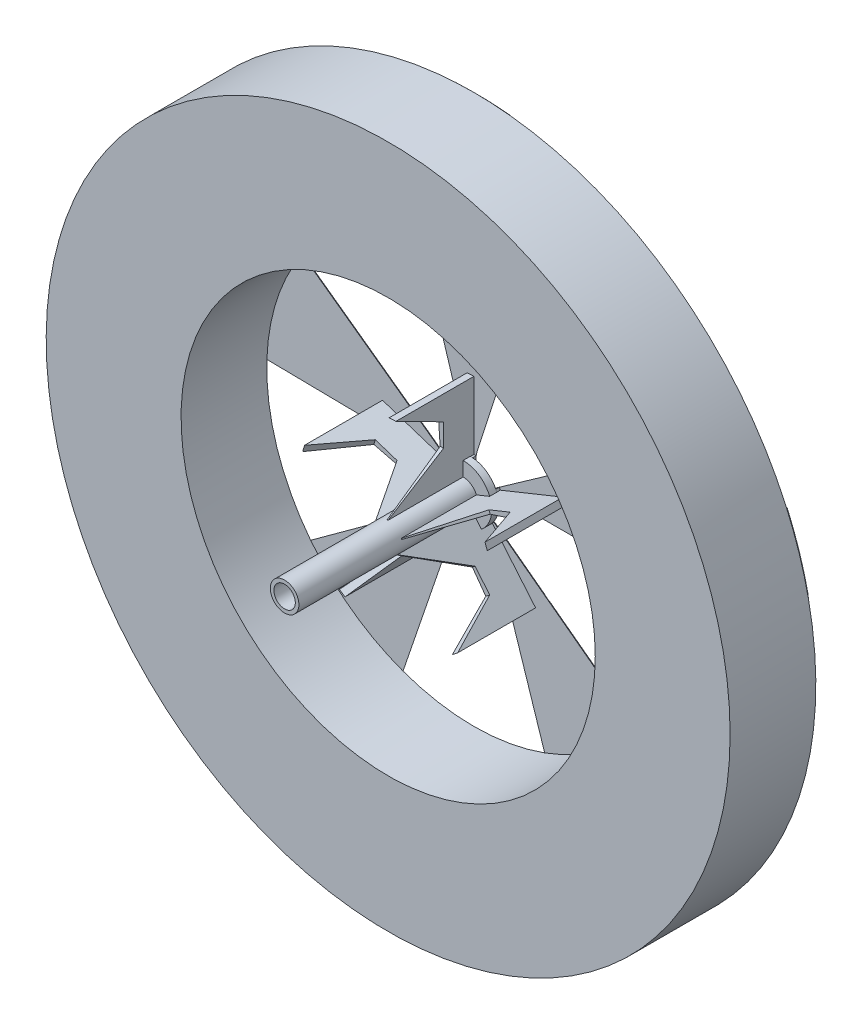
from build123d import *

# Parameters (mm, degrees)
ESQUISSE1_R                  = 47.881441282
ESQUISSE1_R_2                = 28.998911711
BOSS_EXTRU_1_DEPTH           = 12
ESQUISSE3_R                  = 4
BOSS_EXTRU_2_DEPTH           = 1
ESQUISSE4_R                  = 2
ESQUISSE4_R_2                = 1.8
ENL_V_MAT_EXTRU_1_DEPTH      = 0.2
BOSS_EXTRU_3_DEPTH           = 0.3
BOSS_EXTRU_3_TAPER           = 45
BOSS_EXTRU_4_DEPTH           = 0.5
ESQUISSE7_R                  = 0.544673449
ENL_V_MAT_EXTRU_3_DEPTH      = 0.1
ENL_V_MAT_EXTRU_4_DEPTH      = 0.1
ENL_V_MAT_EXTRU_5_DEPTH      = 0.1
R_P_TITION_CIRCULAIRE1_COUNT = 5
ESQUISSE12_R                 = 2
ESQUISSE12_R_2               = 1.5
BOSS_EXTRU_5_DEPTH           = 25
R_VOLUTION1_ANGLE            = 4
R_P_TITION_CIRCULAIRE2_COUNT = 5
ESQUISSE17_R                 = 3.047542713
ESQUISSE17_R_2               = 2
ENL_V_MAT_EXTRU_6_DEPTH      = 25


with BuildPart() as part:
    # Esquisse1 → Boss.-Extru.1 (new body)
    with BuildSketch(Plane.XY):
        Circle(ESQUISSE1_R)
        Circle(ESQUISSE1_R_2, mode=Mode.SUBTRACT)
    extrude(amount=BOSS_EXTRU_1_DEPTH)

    # Esquisse5 → Boss.-Extru.3 (add)
    with BuildSketch(Plane(origin=(0, 0, 0), x_dir=(-1, 0, 0), z_dir=(0, 0, -1))):
        with BuildLine():
            ThreePointArc((5, 47.619664208), (0, 47.881441282), (-5, 47.619664208))
            Line((-5, 47.619664208), (-7.994002033, 27.875308284))
            Line((-7.994002033, 27.875308284), (-0.490252409, 4.669131021))
            Line((-0.490252409, 4.669131021), (-0.319208367, 3.987242909))
            Line((-0.319208367, 3.987242909), (-0.319208367, 3.040119052))
            Line((-0.319208367, 3.040119052), (0.319208367, 3.040119052))
            Line((0.319208367, 3.040119052), (7.994002033, 27.875308284))
            Line((7.994002033, 27.875308284), (5, 47.619664208))
        make_face()
    boss_extru_3 = extrude(amount=BOSS_EXTRU_3_DEPTH, taper=BOSS_EXTRU_3_TAPER)



with BuildPart() as body_2:
    # Esquisse3 → Boss.-Extru.2 (new body)
    with BuildSketch(Plane.XY.offset(0.5)):
        Circle(ESQUISSE3_R)
    extrude(amount=BOSS_EXTRU_2_DEPTH)

    # Esquisse4 → Enlèv. mat.-Extru.1 (cut)
    with BuildSketch(Plane(origin=(0, 0, 0.5), x_dir=(-1, 0, 0), z_dir=(0, 0, -1))):
        Circle(ESQUISSE4_R)
        Circle(ESQUISSE4_R_2, mode=Mode.SUBTRACT)
    extrude(amount=-ENL_V_MAT_EXTRU_1_DEPTH, mode=Mode.SUBTRACT)


with BuildPart() as part_1:
    add(part.part)

    add(body_2.part)  # Boss.-Extru.4 merges body 2
    # Esquisse6 → Boss.-Extru.4 (add)
    with BuildSketch(Plane.XY):
        Polygon((-0.319208367, 3.040119052), (0.319208367, 3.040119052), (0.319208367, 3.987242909), (-0.601770844, 3.954474915), align=None)
    boss_extru_4 = extrude(amount=BOSS_EXTRU_4_DEPTH)

    # Esquisse7 → Enlèv. mat.-Extru.3 (cut)
    with BuildSketch(Plane(origin=(0, 0, -0.3), x_dir=(-1, 0, 0), z_dir=(0, 0, -1))):
        with Locations((0.033792715, 3.733199841)):
            Circle(ESQUISSE7_R)
    enl_v_mat_extru_3 = extrude(amount=-ENL_V_MAT_EXTRU_3_DEPTH, mode=Mode.SUBTRACT)

    # Esquisse10 → Enlèv. mat.-Extru.4 (cut)
    with BuildSketch(Plane(origin=(0, 0, -0.3), x_dir=(-1, 0, 0), z_dir=(0, 0, -1))):
        with BuildLine():
            Line((-0.201712257, 4.751869005), (-0.876503265, 4.751869005))
            Line((-0.876503265, 4.751869005), (1.409084633, 12.47162871))
            Line((1.409084633, 12.47162871), (0, 47.581441282))
            ThreePointArc((0, 47.581441282), (0.242848613, 47.578048894), (0.485719202, 47.578962067))
            Line((0.485719202, 47.578962067), (1.917286295, 11.908959596))
            Line((1.917286295, 11.908959596), (-0.201712257, 4.751869005))
        make_face()
    enl_v_mat_extru_4 = extrude(amount=-ENL_V_MAT_EXTRU_4_DEPTH, mode=Mode.SUBTRACT)

    # Esquisse11 → Enlèv. mat.-Extru.5 (cut)
    with BuildSketch(Plane(origin=(0, 0, -0.3), x_dir=(-1, 0, 0), z_dir=(0, 0, -1))):
        with BuildLine():
            Line((0.621615547, 13.544938302), (2.731676964, 12.196388763))
            Line((2.731676964, 12.196388763), (3.529562356, 13.080114838))
            ThreePointArc((3.529562356, 13.080114838), (2.090235868, 13.404158034), (0.621615547, 13.544938302))
        make_face()
    enl_v_mat_extru_5 = extrude(amount=-ENL_V_MAT_EXTRU_5_DEPTH, mode=Mode.SUBTRACT)

    # Répétition circulaire1: Boss.-Extru.3, Boss.-Extru.4, Enlèv. mat.-Extru.3, Enlèv. mat.-Extru.4, Enlèv. mat.-Extru.5 ×5 about axis
    r_p_tition_circulaire1_axis = Axis((0, 0, 0), (0, 0, 1))
    for i in range(1, R_P_TITION_CIRCULAIRE1_COUNT):
        add(boss_extru_3.rotate(r_p_tition_circulaire1_axis, i * 360 / R_P_TITION_CIRCULAIRE1_COUNT))
        add(boss_extru_4.rotate(r_p_tition_circulaire1_axis, i * 360 / R_P_TITION_CIRCULAIRE1_COUNT))
        add(enl_v_mat_extru_3.rotate(r_p_tition_circulaire1_axis, i * 360 / R_P_TITION_CIRCULAIRE1_COUNT), mode=Mode.SUBTRACT)
        add(enl_v_mat_extru_4.rotate(r_p_tition_circulaire1_axis, i * 360 / R_P_TITION_CIRCULAIRE1_COUNT), mode=Mode.SUBTRACT)
        add(enl_v_mat_extru_5.rotate(r_p_tition_circulaire1_axis, i * 360 / R_P_TITION_CIRCULAIRE1_COUNT), mode=Mode.SUBTRACT)

    # Esquisse12 → Boss.-Extru.5 (add)
    with BuildSketch(Plane.XY.offset(1.5)):
        Circle(ESQUISSE12_R)
        Circle(ESQUISSE12_R_2, mode=Mode.SUBTRACT)
    extrude(amount=BOSS_EXTRU_5_DEPTH)

    # Esquisse16 → Révolution1 (revolve)
    with BuildSketch(Plane(origin=(0, 0, 0), x_dir=(0, 0, -1), z_dir=(1, 0, 0))):
        Polygon((-4.241424431, 6.851544874), (-12, 2), (0, 2), (0, 13.447388523), (-10.913051252, 13.447388523), (-4.241424431, 10.055492122), align=None)
    r_volution1 = revolve(axis=Axis((0, 0, 0), (0, 0, 1)), revolution_arc=R_VOLUTION1_ANGLE)

    # Répétition circulaire2: Révolution1 ×5 about axis
    r_p_tition_circulaire2_axis = Axis((0, 0, 0), (0, 0, 1))
    for i in range(1, R_P_TITION_CIRCULAIRE2_COUNT):
        add(r_volution1.rotate(r_p_tition_circulaire2_axis, i * 360 / R_P_TITION_CIRCULAIRE2_COUNT))

    # Esquisse17 → Enlèv. mat.-Extru.6 (cut)
    with BuildSketch(Plane(origin=(0, 0, 0.5), x_dir=(-1, 0, 0), z_dir=(0, 0, -1))):
        Circle(ESQUISSE17_R)
        Circle(ESQUISSE17_R_2, mode=Mode.SUBTRACT)
    extrude(amount=ENL_V_MAT_EXTRU_6_DEPTH, mode=Mode.SUBTRACT)


solid = part_1.part
